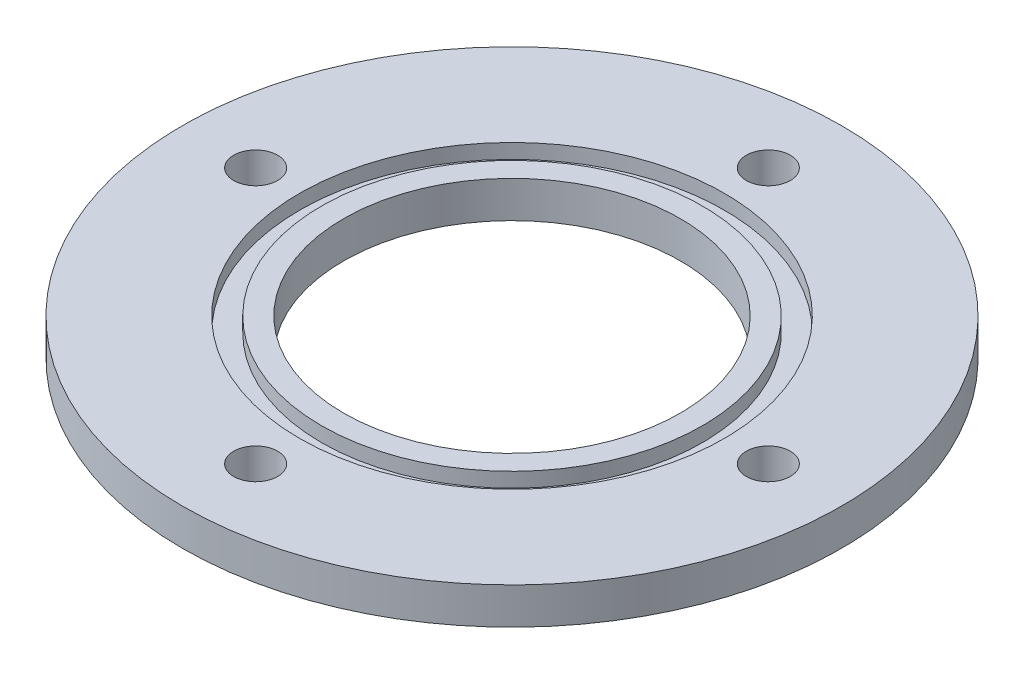
from build123d import *

# Parameters (mm, degrees)
SKETCH_1_R         = 45
SKETCH_1_R_2       = 3
SKETCH_1_R_3       = 23
EXTRUDE_3_DEPTH    = 5
SKETCH1_R          = 29
SKETCH1_R_2        = 26
CUT_EXTRUDE1_DEPTH = 2


with BuildPart() as part:
    # 草圖1 → 填料-伸長3 (new body)
    with BuildSketch(Plane(origin=(0, 0, 0), x_dir=(1, 0, 0), z_dir=(0, 1, 0))):
        Circle(SKETCH_1_R)
        with Locations((-35, 0)):
            Circle(SKETCH_1_R_2, mode=Mode.SUBTRACT)
        with Locations((35, 0)):
            Circle(SKETCH_1_R_2, mode=Mode.SUBTRACT)
        with Locations((0, -35)):
            Circle(SKETCH_1_R_2, mode=Mode.SUBTRACT)
        with Locations((0, 35)):
            Circle(SKETCH_1_R_2, mode=Mode.SUBTRACT)
        Circle(SKETCH_1_R_3, mode=Mode.SUBTRACT)
    extrude(amount=EXTRUDE_3_DEPTH)

    # Sketch1 → Cut-Extrude1 (cut)
    with BuildSketch(Plane(origin=(0, 5, 0), x_dir=(1, 0, 0), z_dir=(0, 1, 0))):
        Circle(SKETCH1_R)
        Circle(SKETCH1_R_2, mode=Mode.SUBTRACT)
    extrude(amount=-CUT_EXTRUDE1_DEPTH, mode=Mode.SUBTRACT)


solid = part.part
